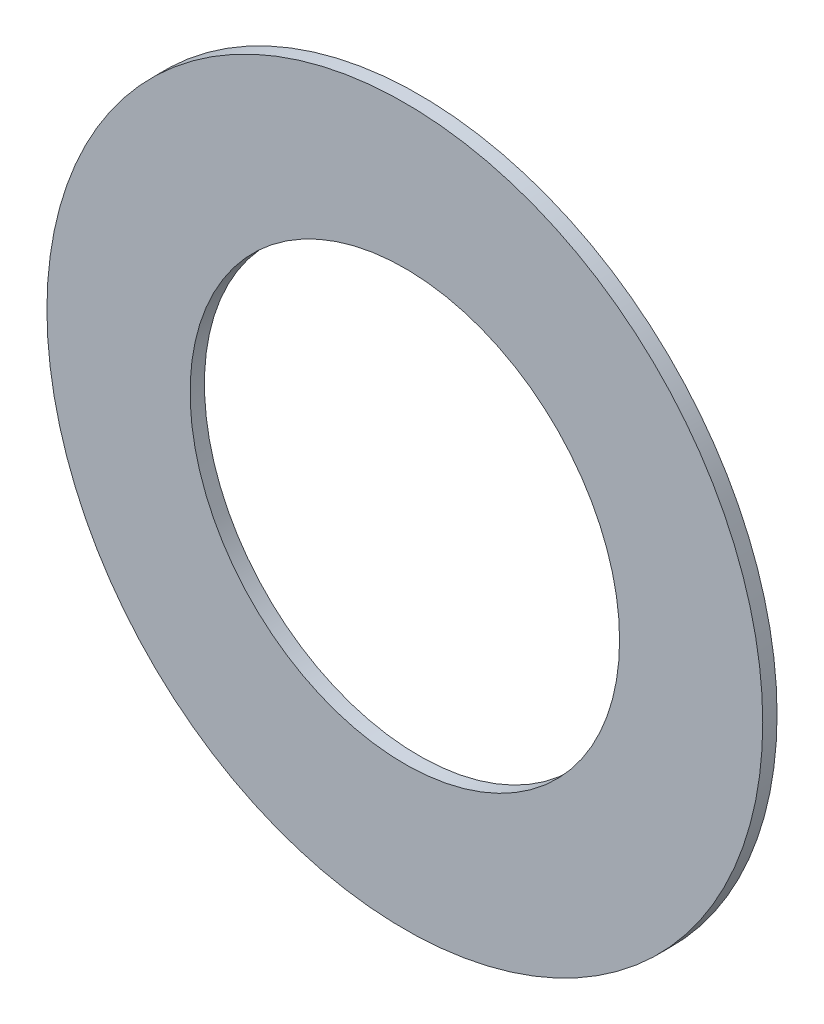
from build123d import *

# Parameters (mm, degrees)
SKETCH_1_R      = 2.5
SKETCH_1_R_2    = 1.5
EXTRUDE_1_DEPTH = 0.05


with BuildPart() as part:
    # 草图1 → 凸台-拉伸1 (new body, symmetric)
    with BuildSketch(Plane.XY):
        Circle(SKETCH_1_R)
        Circle(SKETCH_1_R_2, mode=Mode.SUBTRACT)
    extrude(amount=EXTRUDE_1_DEPTH, both=True)


solid = part.part
